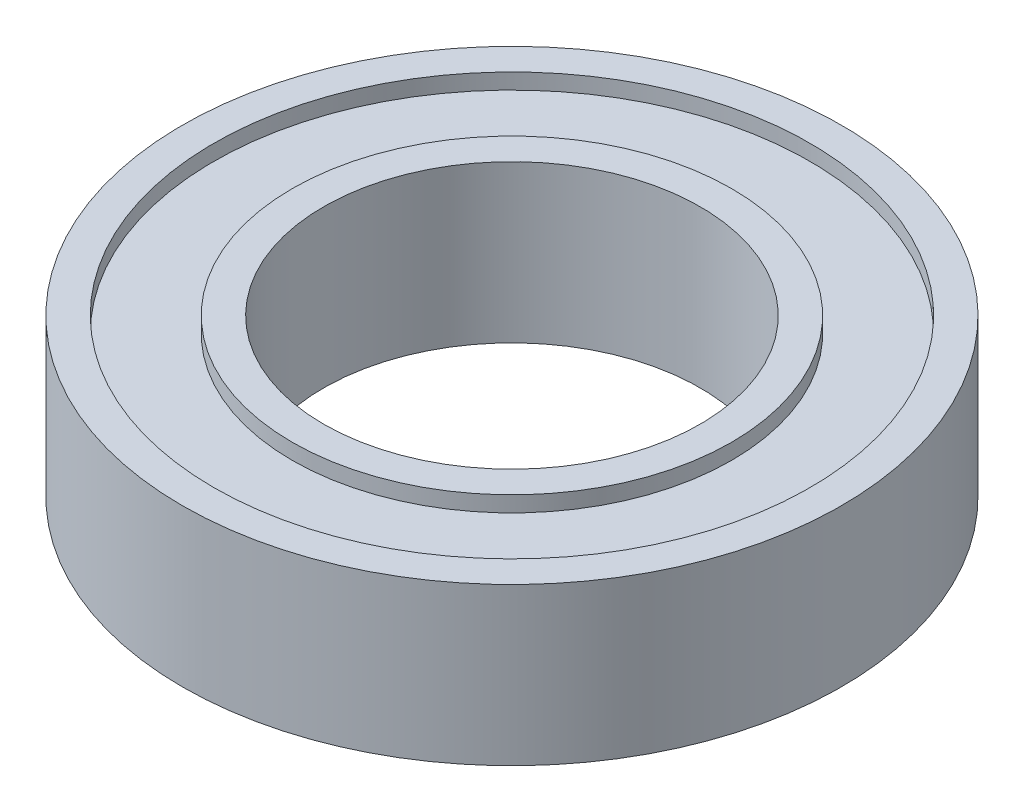
from build123d import *

# Parameters (mm, degrees)
BOSS_EXTRU_1_DEPTH        = 2.5
BOSS_EXTRU_1_DEPTH_BACK   = 2.5
ESQUISSE1_R               = 10.5
ESQUISSE1_R_2             = 9.5
BOSS_EXTRU_1_2_DEPTH      = 2.5
BOSS_EXTRU_1_2_DEPTH_BACK = 2.5
ESQUISSE1_R_3             = 7
ESQUISSE1_R_4             = 6
BOSS_EXTRU_2_DEPTH        = 2
BOSS_EXTRU_2_DEPTH_BACK   = 2
ESQUISSE1_3_R             = 9.5
ESQUISSE1_3_R_2           = 7


with BuildPart() as part:
    # Esquisse1 → Boss.-Extru.1 (new, two sides: drawn at the far end of the back side and taken through both)
    with BuildSketch(Plane(origin=(0, 0, 0), x_dir=(1, 0, 0), z_dir=(0, 1, 0)).offset(-BOSS_EXTRU_1_DEPTH_BACK)):
        Circle(ESQUISSE1_R)
        Circle(ESQUISSE1_R_2, mode=Mode.SUBTRACT)
    extrude(amount=BOSS_EXTRU_1_DEPTH + BOSS_EXTRU_1_DEPTH_BACK)



with BuildPart() as body_2:
    # Esquisse1 → Boss.-Extru.1 2 (new, two sides: drawn at the far end of the back side and taken through both)
    with BuildSketch(Plane(origin=(0, 0, 0), x_dir=(1, 0, 0), z_dir=(0, 1, 0)).offset(-BOSS_EXTRU_1_2_DEPTH_BACK)):
        Circle(ESQUISSE1_R_3)
        Circle(ESQUISSE1_R_4, mode=Mode.SUBTRACT)
    extrude(amount=BOSS_EXTRU_1_2_DEPTH + BOSS_EXTRU_1_2_DEPTH_BACK)


with BuildPart() as part_1:
    add(part.part)

    add(body_2.part)  # Boss.-Extru.2 merges body 2
    # Esquisse1_3 → Boss.-Extru.2 (add, two sides: drawn at the far end of the back side and taken through both)
    with BuildSketch(Plane(origin=(0, 0, 0), x_dir=(1, 0, 0), z_dir=(0, 1, 0)).offset(-BOSS_EXTRU_2_DEPTH_BACK)):
        Circle(ESQUISSE1_3_R)
        Circle(ESQUISSE1_3_R_2, mode=Mode.SUBTRACT)
    extrude(amount=BOSS_EXTRU_2_DEPTH + BOSS_EXTRU_2_DEPTH_BACK)


solid = part_1.part
